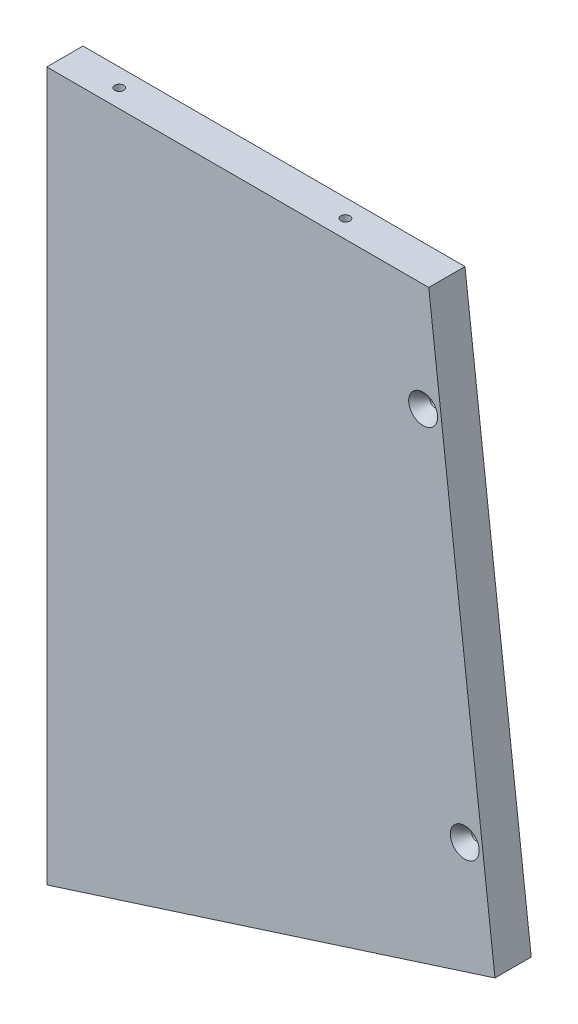
from build123d import *

# Parameters (mm, degrees)
BOSS_EXTRUDE1_DEPTH = 12.7
HOLE3_D             = 3.175
HOLE3_DEPTH         = 31.75
HOLE3_CSINK_D       = 10.16
HOLE3_CSINK_ANGLE   = 82
HOLE3_TIP           = 0.953866233
HOLE6_D             = 3.175
HOLE6_DEPTH         = 38.1
HOLE6_CSINK_D       = 10.16
HOLE6_CSINK_ANGLE   = 82
HOLE6_TIP           = 0.953866233
HOLE7_D             = 3.175
HOLE7_DEPTH         = 31.75
HOLE7_CSINK_D       = 10.16
HOLE7_CSINK_ANGLE   = 82
HOLE7_TIP           = 0.953866233
HOLE8_D             = 3.175
HOLE8_DEPTH         = 31.75
HOLE8_CSINK_D       = 10.16
HOLE8_CSINK_ANGLE   = 82
HOLE8_TIP           = 0.953866233


with BuildPart() as part:
    # Sketch1 → Boss-Extrude1 (new body)
    with BuildSketch(Plane.XY):
        Polygon((-88.190159952, 0), (-222.052967181, 0), (-222.052967181, -248.25), (-64.977416983, -197.966048293), align=None)
    extrude(amount=-BOSS_EXTRUDE1_DEPTH)

    # Hole3
    with Locations(Plane(origin=(-234.752967181, 1090.512770337, -135.816741379), x_dir=(0, 0, -1), z_dir=(-1, 0, 0))):
        with Locations((-129.466741379, 1300.662770337), (-129.466741379, 1128.612770337), (129.198788767, 1128.612770337), (129.198788767, 1300.662770337)):
            CounterSinkHole(HOLE3_D / 2, HOLE3_CSINK_D / 2, depth=HOLE3_DEPTH, counter_sink_angle=HOLE3_CSINK_ANGLE)
            with Locations((0, 0, -(HOLE3_DEPTH + HOLE3_TIP / 2))):  # 118° drill point
                Cone(0, HOLE3_D / 2, HOLE3_TIP, mode=Mode.SUBTRACT)

    # Hole6
    with Locations(Plane(origin=(181.039434513, 1090.512770337, 0), x_dir=(-0.927183855, -0.374606593, 0), z_dir=(0, 0, 1))):
        with Locations((707.166557203, 1065.270372796), (674.127983646, 944.603090451)):
            CounterSinkHole(HOLE6_D / 2, HOLE6_CSINK_D / 2, depth=HOLE6_DEPTH, counter_sink_angle=HOLE6_CSINK_ANGLE)
            with Locations((0, 0, -(HOLE6_DEPTH + HOLE6_TIP / 2))):  # 118° drill point
                Cone(0, HOLE6_D / 2, HOLE6_TIP, mode=Mode.SUBTRACT)

    # Hole7
    with Locations(Plane(origin=(181.039434513, 12.7, -135.816741379), x_dir=(0, 0, -1), z_dir=(0, 1, 0))):
        with Locations((129.198788767, 384.042401694), (-129.466741379, 384.042401694), (-129.466741379, 304.786761906), (-110.416741379, 409.442401694), (-0.133976306, 409.442401694), (110.148788767, 409.442401694), (129.198788767, 304.786761906)):
            CounterSinkHole(HOLE7_D / 2, HOLE7_CSINK_D / 2, depth=HOLE7_DEPTH, counter_sink_angle=HOLE7_CSINK_ANGLE)
            with Locations((0, 0, -(HOLE7_DEPTH + HOLE7_TIP / 2))):  # 118° drill point
                Cone(0, HOLE7_D / 2, HOLE7_TIP, mode=Mode.SUBTRACT)

    # Hole8
    with Locations(Plane(origin=(536.177050645, -18.855816567, -135.816741379), x_dir=(0, 0, 1), z_dir=(0.304884492, -0.952389336, 0))):
        with Locations((-129.257383629, 766.263727577), (129.466741379, 668.242950575), (129.466741379, 766.064256541), (-129.408220012, 668.442537903)):
            CounterSinkHole(HOLE8_D / 2, HOLE8_CSINK_D / 2, depth=HOLE8_DEPTH, counter_sink_angle=HOLE8_CSINK_ANGLE)
            with Locations((0, 0, -(HOLE8_DEPTH + HOLE8_TIP / 2))):  # 118° drill point
                Cone(0, HOLE8_D / 2, HOLE8_TIP, mode=Mode.SUBTRACT)


solid = part.part
